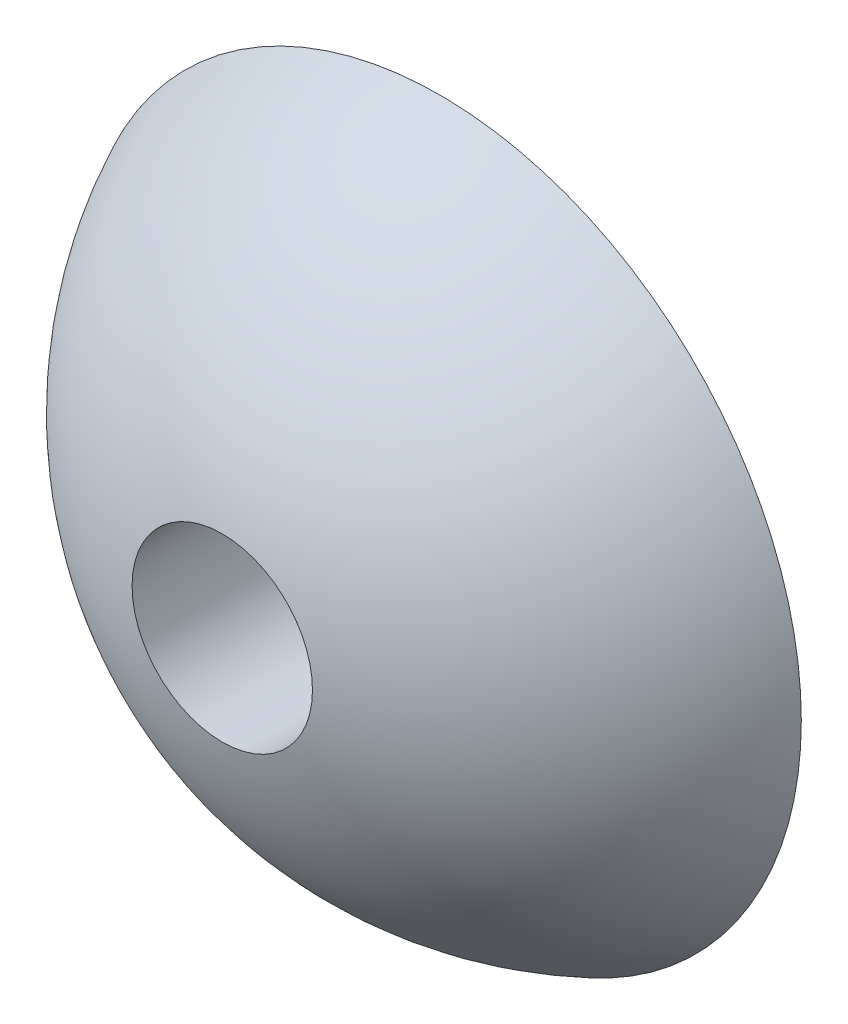
from build123d import *

# Parameters (mm, degrees)
SKETCH6_R           = 22.5
SKETCH6_R_2         = 1
CUT_EXTRUDE8_DEPTH  = 20
SKETCH7_R           = 7.9
CUT_EXTRUDE9_DEPTH  = 20
SKETCH9_W           = 74.911016849
SKETCH9_H           = 74.606087337
CUT_EXTRUDE11_DEPTH = 50


with BuildPart() as part:
    # Sketch2 → Revolve1 (revolve)
    with BuildSketch(Plane.XY):
        with BuildLine():
            Line((0, 0), (70, 0))
            ThreePointArc((70, 0), (35, 35), (0, 0))
        make_face()
    revolve(axis=Axis((0, 0, 0), (1, 0, 0)))

    # Sketch6 → Cut-Extrude8 (cut)
    with BuildSketch(Plane.XY.offset(-5)):
        with Locations((35, -7)):
            Circle(SKETCH6_R)
        with Locations((17.5, -7)):
            Circle(SKETCH6_R_2, mode=Mode.SUBTRACT)
        with Locations((52.5, -7)):
            Circle(SKETCH6_R_2, mode=Mode.SUBTRACT)
    extrude(amount=CUT_EXTRUDE8_DEPTH, mode=Mode.SUBTRACT)

    # Sketch7 → Cut-Extrude9 (cut)
    with BuildSketch(Plane.XY.offset(35)):
        with Locations((35, 0)):
            Circle(SKETCH7_R)
    extrude(amount=-CUT_EXTRUDE9_DEPTH, mode=Mode.SUBTRACT)

    # Sketch9 → Cut-Extrude11 (cut)
    with BuildSketch(Plane.XY.offset(-35)):
        with Locations((35.457394269, -0.10164317)):
            Rectangle(SKETCH9_W, SKETCH9_H)
    extrude(amount=CUT_EXTRUDE11_DEPTH, mode=Mode.SUBTRACT)


solid = part.part
